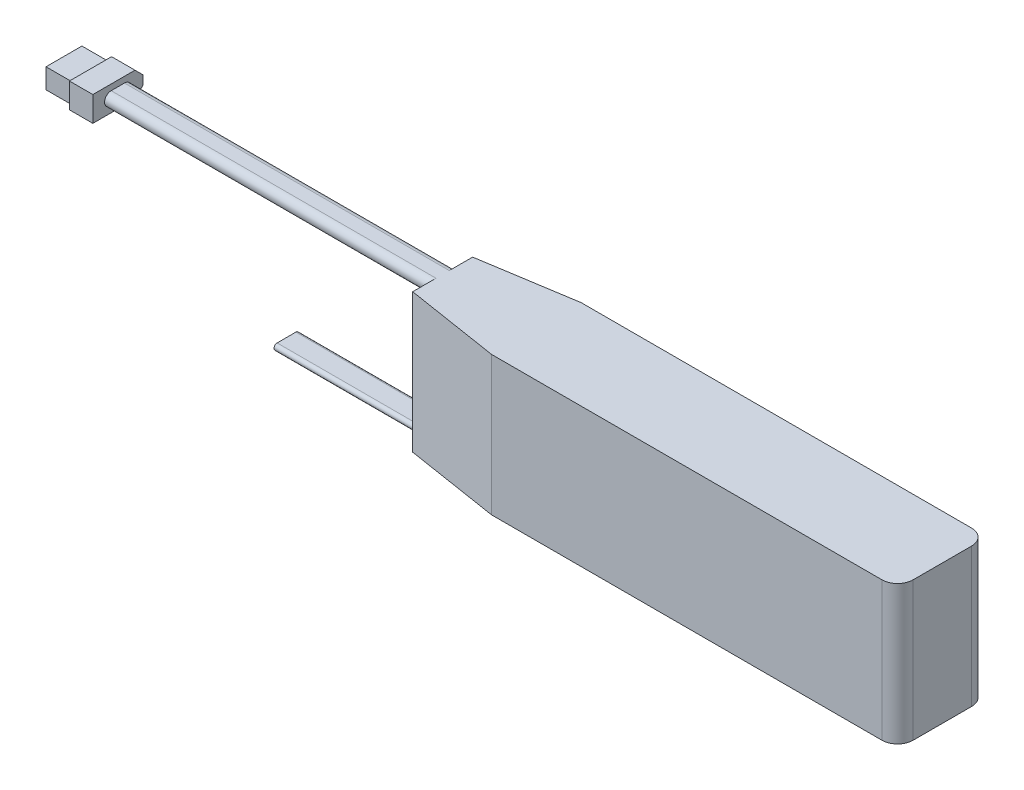
from build123d import *
from OCP.BRepFilletAPI import BRepFilletAPI_MakeChamfer

# Parameters (mm, degrees)
SKETCH_1_W          = 160
SKETCH_1_H          = 44.5
EXTRUDE_1_DEPTH     = 28.7
FILLET_1_R          = 5
CHAMFER_1_SIZE      = 30
CHAMFER_1_SIZE2     = 4.75153321
EXTRUDE_6_DEPTH     = 120
EXTRUDE_7_DEPTH     = 50
EXTRUDE_8_DEPTH     = 7.5
SKETCH_3_3_R        = 1.75
EXTRUDE_9_DEPTH     = 16
SKETCH_4_R          = 1.75
CUT_EXTRUDE_1_DEPTH = 8


with BuildPart() as part:
    # 草圖1 → 填料-伸長1 (new body)
    with BuildSketch(Plane.XY):
        with Locations((80, 22.25)):
            Rectangle(SKETCH_1_W, SKETCH_1_H)
    extrude(amount=EXTRUDE_1_DEPTH)

    # 圓角1
    fillet_1_edges = [part.edges().sort_by_distance(p)[0] for p in [
        (160, 22.25, 0),
        (160, 22.25, 28.7),
    ]]
    fillet(fillet_1_edges, radius=FILLET_1_R)

    # 導角1: one chamfer whose edges measure the first distance from different faces: ONE call of the kernel's chamfer builder (chamfer() names one face for all edges)
    chamfer_1_edges_1 = [part.edges().sort_by_distance(p)[0] for p in [
        (0, 22.25, 28.7),
    ]]
    chamfer_1_side_1 = [part.faces().sort_by_distance(p)[0] for p in [
        (77.5, 22.25, 28.7),
    ]]
    chamfer_1_edges_2 = [part.edges().sort_by_distance(p)[0] for p in [
        (0, 22.25, 0),
    ]]
    chamfer_1_side_2 = [part.faces().sort_by_distance(p)[0] for p in [
        (77.5, 22.25, 0),
    ]]
    chamfer_1 = BRepFilletAPI_MakeChamfer(part.part.solid().wrapped)
    for e in chamfer_1_edges_1:
        chamfer_1.Add(CHAMFER_1_SIZE, CHAMFER_1_SIZE2, e.wrapped, chamfer_1_side_1[0].wrapped)  # the first distance lies on this face
    for e in chamfer_1_edges_2:
        chamfer_1.Add(CHAMFER_1_SIZE, CHAMFER_1_SIZE2, e.wrapped, chamfer_1_side_2[0].wrapped)  # the first distance lies on this face
    add(Compound.cast(chamfer_1.Shape()), mode=Mode.REPLACE)

    # 草圖2 → 填料-伸長6 (add)
    with BuildSketch(Plane.ZY):
        with BuildLine():
            Line((16.475, 44.5), (12.225, 44.5))
            ThreePointArc((12.225, 44.5), (10.1, 42.375), (12.225, 40.25))
            Line((12.225, 40.25), (16.474999883, 40.25))
            ThreePointArc((16.474999883, 40.25), (18.6, 42.374999942), (16.475, 44.5))
        make_face()
    extrude(amount=EXTRUDE_6_DEPTH)

    # 草圖2<3> → 填料-伸長7 (add)
    with BuildSketch(Plane.ZY):
        with BuildLine():
            ThreePointArc((11.35, 2), (10.35, 1), (11.35, 0))
            Line((11.35, 0), (17.35, 0))
            ThreePointArc((17.35, 0), (18.35, 1), (17.35, 2))
            Line((17.35, 2), (11.35, 2))
        make_face()
    extrude(amount=EXTRUDE_7_DEPTH)

    # 草圖3 → 填料-伸長8 (add)
    with BuildSketch(Plane.ZY.offset(104)):
        Polygon((22.35, 46.375), (8.85, 46.375), (6.35, 43.875), (6.35, 40.875), (8.85, 38.375), (22.35, 38.375), align=None)
    extrude(amount=EXTRUDE_8_DEPTH)

    # 草圖3<3> → 填料-伸長9 (add)
    with BuildSketch(Plane.ZY.offset(104)):
        Polygon((9.85, 45.575), (7.35, 43.075), (7.35, 41.675), (9.85, 39.175), (14.11665296, 39.175), (14.11665296, 40.489122918), (14.746028023, 40.489122918), (14.746028023, 39.175), (21.35, 39.175), (21.35, 45.575), align=None)
        with Locations((12.225, 42.375)):
            Circle(SKETCH_3_3_R, mode=Mode.SUBTRACT)
        with Locations((16.475, 42.375)):
            Circle(SKETCH_3_3_R, mode=Mode.SUBTRACT)
    extrude(amount=EXTRUDE_9_DEPTH)

    # 草圖4 → 除料-伸長1 (cut)
    with BuildSketch(Plane.ZY.offset(120)):
        with Locations((11.633674327, 42.375)):
            Circle(SKETCH_4_R)
        with Locations((17.123250996, 42.375)):
            Circle(SKETCH_4_R)
    extrude(amount=-CUT_EXTRUDE_1_DEPTH, mode=Mode.SUBTRACT)


solid = part.part
